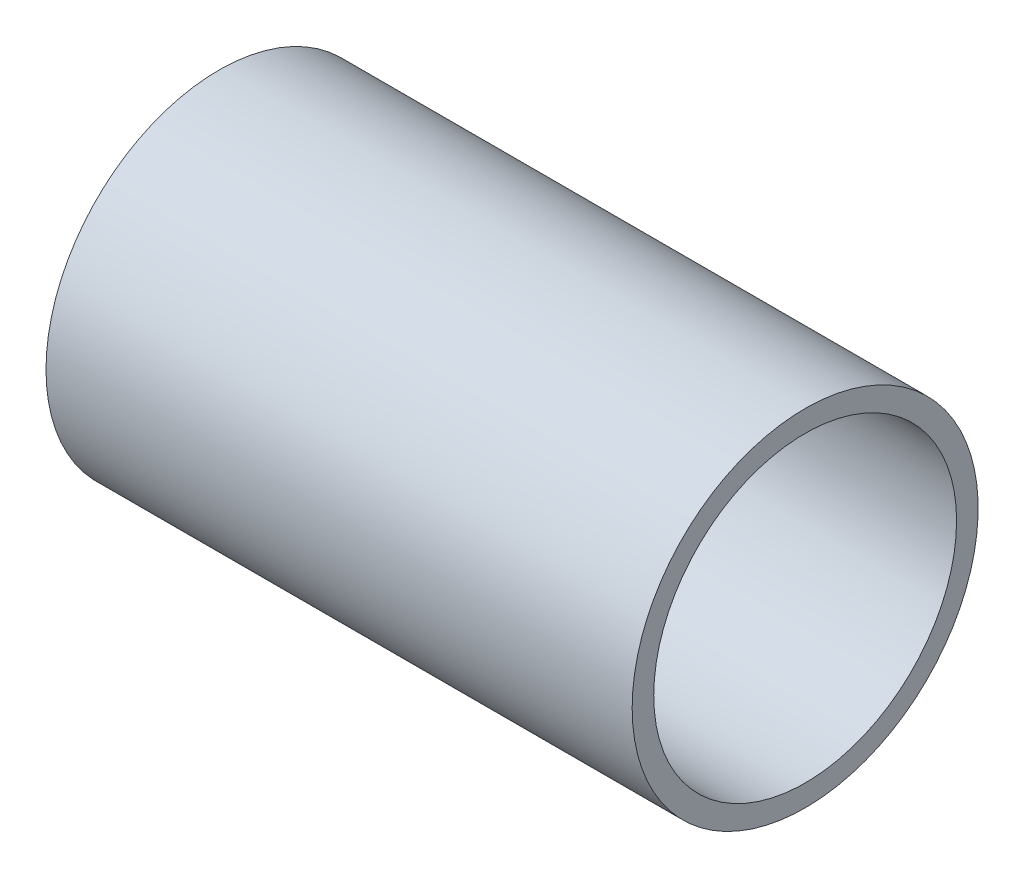
from build123d import *

# Parameters (mm, degrees)
SKETCH2_W = 548.64
SKETCH2_H = 20.193


with BuildPart() as part:
    # Sketch2 → Revolve1 (revolve)
    with BuildSketch(Plane.XY):
        with Locations((274.32, 151.8285)):
            Rectangle(SKETCH2_W, SKETCH2_H)
    revolve(axis=Axis((0, 0, 0), (1, 0, 0)))


solid = part.part
